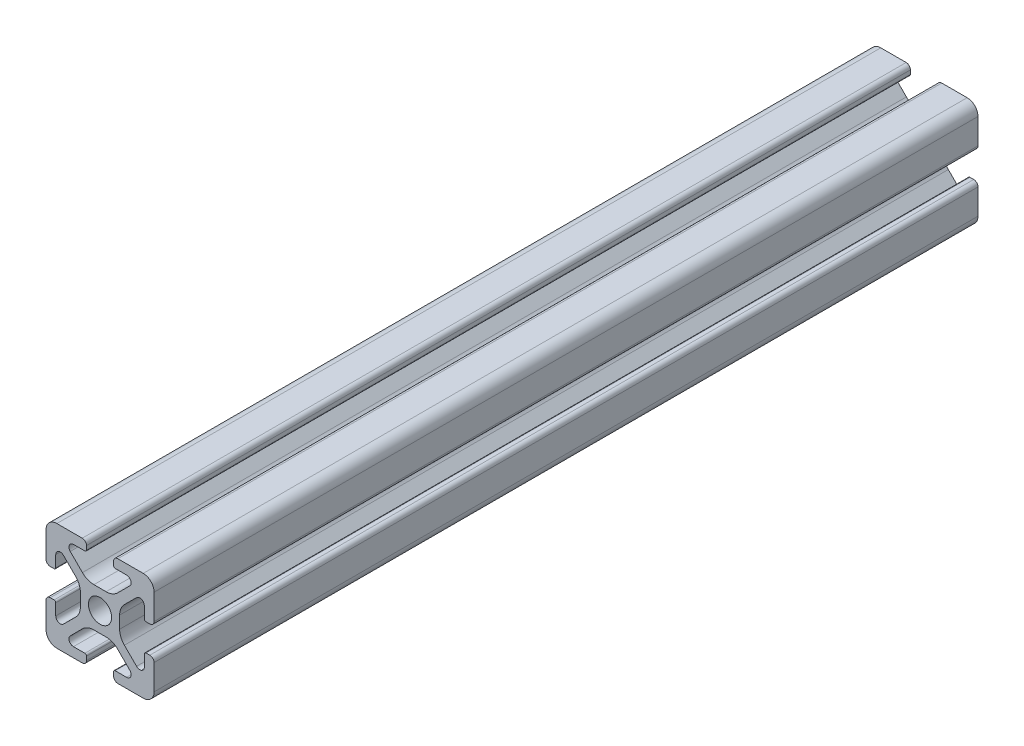
from build123d import *

# Parameters (mm, degrees)
SKETCH1_R           = 2.1463
BOSS_EXTRUDE1_DEPTH = 152.4
SKETCH2_W           = 30.13801893
SKETCH2_H           = 25.969901185
CUT_EXTRUDE1_DEPTH  = 152.4


with BuildPart() as part:
    # Sketch1 → Boss-Extrude1 (new body, symmetric)
    with BuildSketch(Plane.XY):
        with BuildLine():
            Line((-9.9949, 7.9883), (-9.9949, 3.2893))
            ThreePointArc((-9.9949, 3.2893), (-9.76427588, 2.73252412), (-9.2075, 2.5019))
            Line((-9.2075, 2.5019), (-8.4963, 2.5019))
            ThreePointArc((-8.4963, 2.5019), (-8.280773853, 2.591173853), (-8.1915, 2.8067))
            Line((-8.1915, 2.8067), (-8.1915, 4.9149))
            ThreePointArc((-8.1915, 4.9149), (-7.674065253, 5.689295824), (-6.760603096, 5.507596904))
            Line((-6.760603096, 5.507596904), (-4.505765747, 3.252759555))
            ThreePointArc((-4.505765747, 3.252759555), (-3.856054457, 2.280397894), (-3.627906192, 1.133419111))
            Line((-3.627906192, 1.133419111), (-3.627906192, -1.133419111))
            ThreePointArc((-3.627906192, -1.133419111), (-3.856054457, -2.280397894), (-4.505765747, -3.252759555))
            Line((-4.505765747, -3.252759555), (-6.760603096, -5.507596904))
            ThreePointArc((-6.760603096, -5.507596904), (-7.674065253, -5.689295824), (-8.1915, -4.9149))
            Line((-8.1915, -4.9149), (-8.1915, -2.8067))
            ThreePointArc((-8.1915, -2.8067), (-8.280773853, -2.591173853), (-8.4963, -2.5019))
            Line((-8.4963, -2.5019), (-9.2075, -2.5019))
            ThreePointArc((-9.2075, -2.5019), (-9.76427588, -2.73252412), (-9.9949, -3.2893))
            Line((-9.9949, -3.2893), (-9.9949, -7.9883))
            ThreePointArc((-9.9949, -7.9883), (-9.407180467, -9.407180467), (-7.9883, -9.9949))
            Line((-7.9883, -9.9949), (-3.2893, -9.9949))
            ThreePointArc((-3.2893, -9.9949), (-2.73252412, -9.76427588), (-2.5019, -9.2075))
            Line((-2.5019, -9.2075), (-2.5019, -8.4963))
            ThreePointArc((-2.5019, -8.4963), (-2.591173853, -8.280773853), (-2.8067, -8.1915))
            Line((-2.8067, -8.1915), (-4.9149, -8.1915))
            ThreePointArc((-4.9149, -8.1915), (-5.689295824, -7.674065253), (-5.507596904, -6.760603096))
            Line((-5.507596904, -6.760603096), (-3.252759555, -4.505765747))
            ThreePointArc((-3.252759555, -4.505765747), (-2.280397894, -3.856054457), (-1.133419111, -3.627906192))
            Line((-1.133419111, -3.627906192), (1.133419111, -3.627906192))
            ThreePointArc((1.133419111, -3.627906192), (2.280397894, -3.856054457), (3.252759555, -4.505765747))
            Line((3.252759555, -4.505765747), (5.507596904, -6.760603096))
            ThreePointArc((5.507596904, -6.760603096), (5.689295824, -7.674065253), (4.9149, -8.1915))
            Line((4.9149, -8.1915), (2.8067, -8.1915))
            ThreePointArc((2.8067, -8.1915), (2.591173853, -8.280773853), (2.5019, -8.4963))
            Line((2.5019, -8.4963), (2.5019, -9.2075))
            ThreePointArc((2.5019, -9.2075), (2.73252412, -9.76427588), (3.2893, -9.9949))
            Line((3.2893, -9.9949), (7.9883, -9.9949))
            ThreePointArc((7.9883, -9.9949), (9.407180467, -9.407180467), (9.9949, -7.9883))
            Line((9.9949, -7.9883), (9.9949, -3.2893))
            ThreePointArc((9.9949, -3.2893), (9.76427588, -2.73252412), (9.2075, -2.5019))
            Line((9.2075, -2.5019), (8.4963, -2.5019))
            ThreePointArc((8.4963, -2.5019), (8.280773853, -2.591173853), (8.1915, -2.8067))
            Line((8.1915, -2.8067), (8.1915, -4.9149))
            ThreePointArc((8.1915, -4.9149), (7.674065253, -5.689295824), (6.760603096, -5.507596904))
            Line((6.760603096, -5.507596904), (4.505765747, -3.252759555))
            ThreePointArc((4.505765747, -3.252759555), (3.856054457, -2.280397894), (3.627906192, -1.133419111))
            Line((3.627906192, -1.133419111), (3.627906192, 1.133419111))
            ThreePointArc((3.627906192, 1.133419111), (3.856054457, 2.280397894), (4.505765747, 3.252759555))
            Line((4.505765747, 3.252759555), (6.760603096, 5.507596904))
            ThreePointArc((6.760603096, 5.507596904), (7.674065253, 5.689295824), (8.1915, 4.9149))
            Line((8.1915, 4.9149), (8.1915, 2.8067))
            ThreePointArc((8.1915, 2.8067), (8.280773853, 2.591173853), (8.4963, 2.5019))
            Line((8.4963, 2.5019), (9.2075, 2.5019))
            ThreePointArc((9.2075, 2.5019), (9.76427588, 2.73252412), (9.9949, 3.2893))
            Line((9.9949, 3.2893), (9.9949, 7.9883))
            ThreePointArc((9.9949, 7.9883), (9.407180467, 9.407180467), (7.9883, 9.9949))
            Line((7.9883, 9.9949), (3.2893, 9.9949))
            ThreePointArc((3.2893, 9.9949), (2.73252412, 9.76427588), (2.5019, 9.2075))
            Line((2.5019, 9.2075), (2.5019, 8.4963))
            ThreePointArc((2.5019, 8.4963), (2.591173853, 8.280773853), (2.8067, 8.1915))
            Line((2.8067, 8.1915), (4.9149, 8.1915))
            ThreePointArc((4.9149, 8.1915), (5.689295824, 7.674065253), (5.507596904, 6.760603096))
            Line((5.507596904, 6.760603096), (3.252759555, 4.505765747))
            ThreePointArc((3.252759555, 4.505765747), (2.280397894, 3.856054457), (1.133419111, 3.627906192))
            Line((1.133419111, 3.627906192), (-1.133419111, 3.627906192))
            ThreePointArc((-1.133419111, 3.627906192), (-2.280397894, 3.856054457), (-3.252759555, 4.505765747))
            Line((-3.252759555, 4.505765747), (-5.507596904, 6.760603096))
            ThreePointArc((-5.507596904, 6.760603096), (-5.689295824, 7.674065253), (-4.9149, 8.1915))
            Line((-4.9149, 8.1915), (-2.8067, 8.1915))
            ThreePointArc((-2.8067, 8.1915), (-2.591173853, 8.280773853), (-2.5019, 8.4963))
            Line((-2.5019, 8.4963), (-2.5019, 9.2075))
            ThreePointArc((-2.5019, 9.2075), (-2.73252412, 9.76427588), (-3.2893, 9.9949))
            Line((-3.2893, 9.9949), (-7.9883, 9.9949))
            ThreePointArc((-7.9883, 9.9949), (-9.407180467, 9.407180467), (-9.9949, 7.9883))
        make_face()
        Circle(SKETCH1_R, mode=Mode.SUBTRACT)
    extrude(amount=BOSS_EXTRUDE1_DEPTH, both=True)

    # Sketch2 → Cut-Extrude1 (cut)
    with BuildSketch(Plane.XY.offset(152.4)):
        with Locations((0.230542333, -0.84546573)):
            Rectangle(SKETCH2_W, SKETCH2_H)
    extrude(amount=-CUT_EXTRUDE1_DEPTH, mode=Mode.SUBTRACT)


solid = part.part
